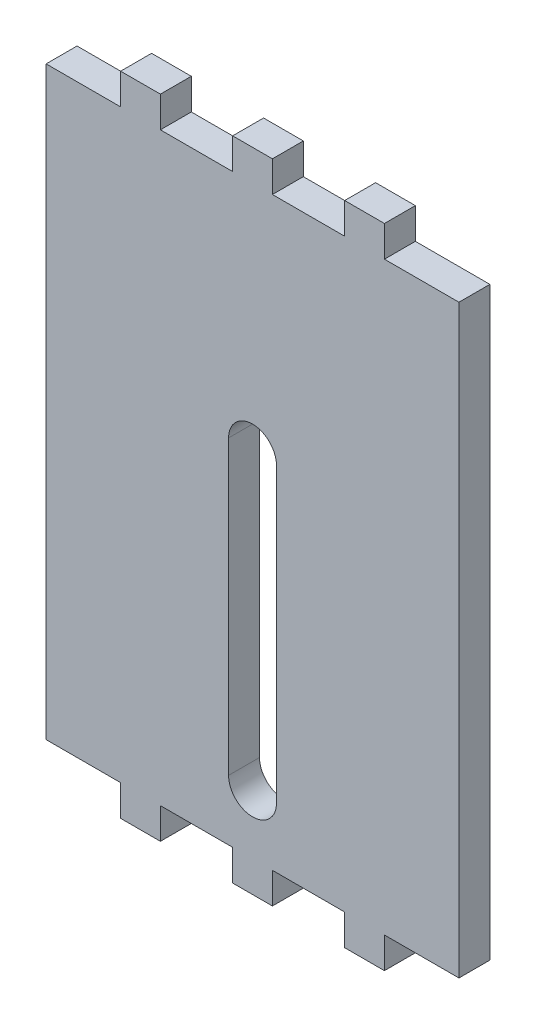
from build123d import *

# Parameters (mm, degrees)
BOSS_EXTRUDE1_DEPTH = 3.175
BOSS_EXTRUDE2_DEPTH = 3.175


with BuildPart() as part:
    # Sketch1 → Boss-Extrude1 (new body)
    with BuildSketch(Plane.XY):
        Polygon((-13.5, 38.85), (-21.15, 38.85), (-21.15, -21.15), (-13.5, -21.15), (-13.5, -24.325), (-9.5, -24.325), (-9.5, -21.15), (-2, -21.15), (-2, -24.325), (2, -24.325), (2, -21.15), (9.5, -21.15), (9.5, -24.325), (13.5, -24.325), (13.5, -21.15), (21.15, -21.15), (21.15, 38.85), (13.5, 38.85), (13.5, 42.025), (9.5, 42.025), (9.5, 38.85), (2, 38.85), (2, 42.025), (-2, 42.025), (-2, 38.85), (-9.5, 38.85), (-9.5, 42.025), (-13.5, 42.025), align=None)
        with BuildLine():
            Line((-2.5, -15), (-2.5, 15))
            ThreePointArc((-2.5, 15), (0, 17.5), (2.5, 15))
            Line((2.5, 15), (2.5, -15))
            ThreePointArc((2.5, -15), (0, -17.5), (-2.5, -15))
        make_face(mode=Mode.SUBTRACT)
    extrude(amount=BOSS_EXTRUDE1_DEPTH)

    # Sketch2 → Boss-Extrude2 (add)
    with BuildSketch(Plane.XY.offset(3.175)):
        Polygon((21.19064, -21.19064), (21.19064, 38.89064), (13.54064, 38.89064), (13.54064, 42.06564), (9.45936, 42.06564), (9.45936, 38.89064), (2.04064, 38.89064), (2.04064, 42.06564), (-2.04064, 42.06564), (-2.04064, 38.89064), (-9.45936, 38.89064), (-9.45936, 42.06564), (-13.54064, 42.06564), (-13.54064, 38.89064), (-21.19064, 38.89064), (-21.19064, -21.19064), (-13.54064, -21.19064), (-13.54064, -24.36564), (-9.45936, -24.36564), (-9.45936, -21.19064), (-2.04064, -21.19064), (-2.04064, -24.36564), (2.04064, -24.36564), (2.04064, -21.19064), (9.45936, -21.19064), (9.45936, -24.36564), (13.54064, -24.36564), (13.54064, -21.19064), align=None)
        with BuildLine():
            Line((-2.45936, 15), (-2.45936, -15))
            ThreePointArc((-2.45936, -15), (0, -17.45936), (2.45936, -15))
            Line((2.45936, -15), (2.45936, 15))
            ThreePointArc((2.45936, 15), (0, 17.45936), (-2.45936, 15))
        make_face(mode=Mode.SUBTRACT)
    extrude(amount=-BOSS_EXTRUDE2_DEPTH)


solid = part.part
